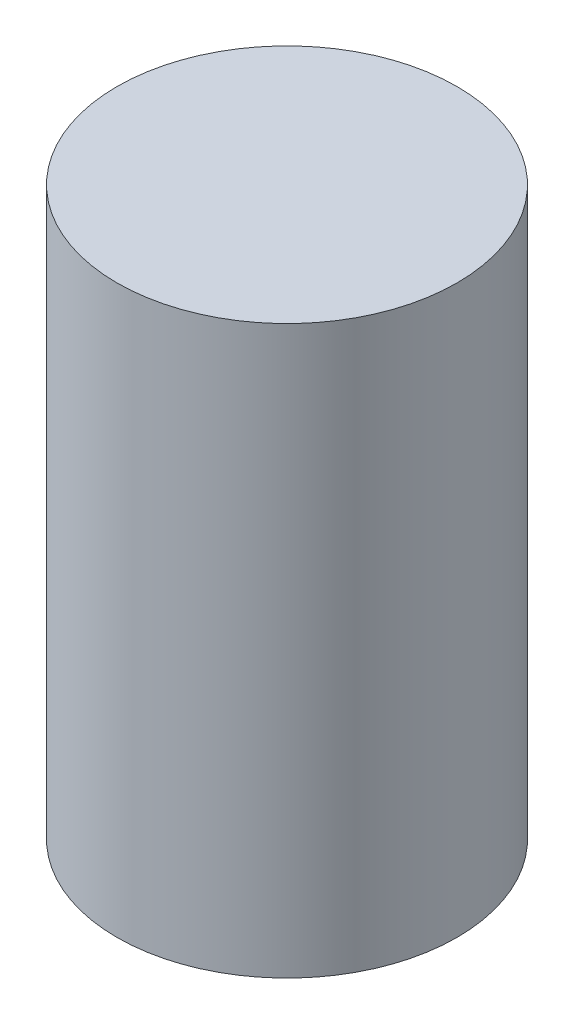
from build123d import *

# Parameters (mm, degrees)
SKETCH1_R           = 1.5
BOSS_EXTRUDE1_DEPTH = 5


with BuildPart() as part:
    # Sketch1 → Boss-Extrude1 (new body)
    with BuildSketch(Plane(origin=(0, 0, 0), x_dir=(1, 0, 0), z_dir=(0, 1, 0))):
        Circle(SKETCH1_R)
    extrude(amount=BOSS_EXTRUDE1_DEPTH)


solid = part.part
